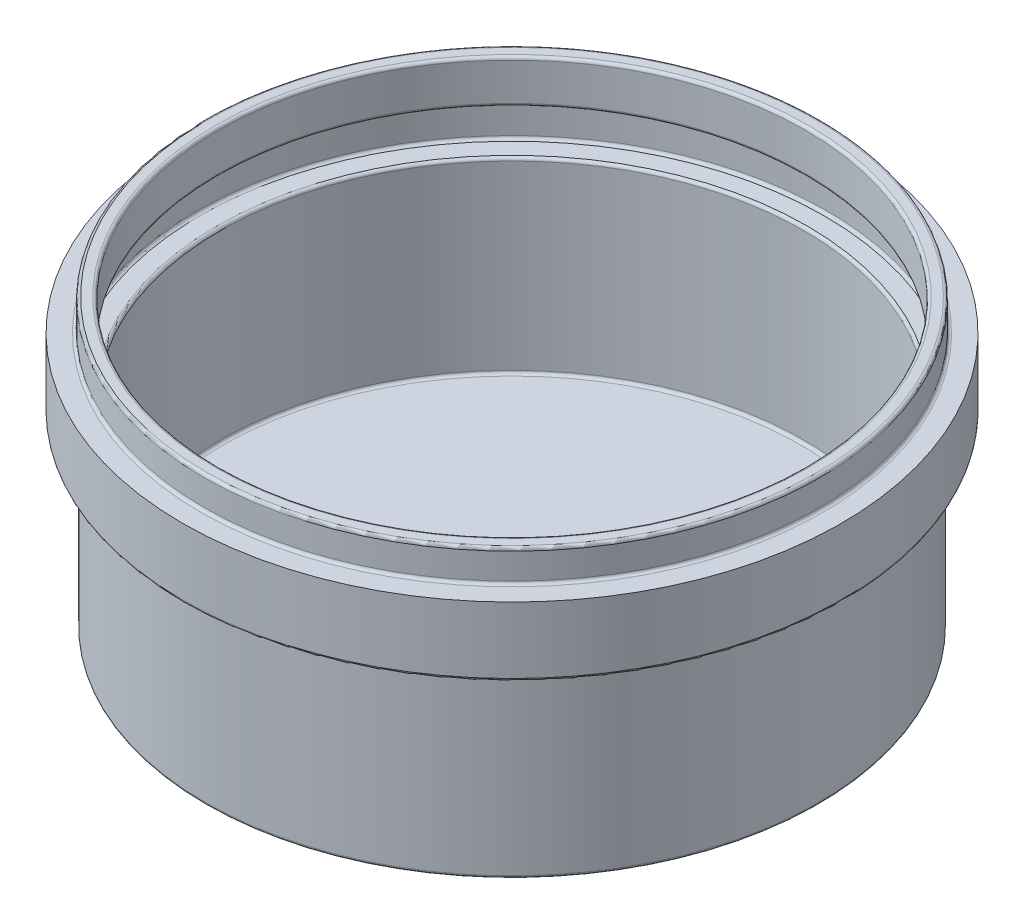
from build123d import *

# Parameters (mm, degrees)
ESBO_O1_R                = 53.25
RESSALTO_EXTRUS_O1_DEPTH = 2.5
ESBO_O2_R                = 53.25
ESBO_O2_R_2              = 50.75
RESSALTO_EXTRUS_O2_DEPTH = 30
ESBO_O3_R                = 57.25
RESSALTO_EXTRUS_O3_DEPTH = 12
ESBO_O6_R                = 53.5
RESSALTO_EXTRUS_O4_DEPTH = 5.5
ESBO_O7_R                = 51
CORTE_EXTRUS_O4_DEPTH    = 7.5
ESBO_O8_R                = 54.75
CORTE_EXTRUS_O5_DEPTH    = 7.5
CORTE_EXTRUS_O6_START    = -7.5
ESBO_O9_R                = 50.75
CORTE_EXTRUS_O6_DEPTH    = 7.5
FILETE1_R                = 0.5
FILETE2_R                = 0.5


with BuildPart() as part:
    # Esboço1 → Ressalto-extrusão1 (new body)
    with BuildSketch(Plane(origin=(0, 0, 0), x_dir=(1, 0, 0), z_dir=(0, 1, 0))):
        Circle(ESBO_O1_R)
    extrude(amount=RESSALTO_EXTRUS_O1_DEPTH)

    # Esboço2 → Ressalto-extrusão2 (add)
    with BuildSketch(Plane(origin=(0, 2.5, 0), x_dir=(1, 0, 0), z_dir=(0, 1, 0))):
        Circle(ESBO_O2_R)
        Circle(ESBO_O2_R_2, mode=Mode.SUBTRACT)
    extrude(amount=RESSALTO_EXTRUS_O2_DEPTH)


with BuildPart() as body_2:
    # Esboço3 → Ressalto-extrusão3 (new body)
    with BuildSketch(Plane(origin=(0, 32.5, 0), x_dir=(1, 0, 0), z_dir=(0, 1, 0))):
        Circle(ESBO_O3_R)
    extrude(amount=RESSALTO_EXTRUS_O3_DEPTH)

    # Esboço6 → Ressalto-extrusão4 (add)
    with BuildSketch(Plane(origin=(0, 44.5, 0), x_dir=(1, 0, 0), z_dir=(0, 1, 0))):
        Circle(ESBO_O6_R)
    extrude(amount=RESSALTO_EXTRUS_O4_DEPTH)

    # Esboço7 → Corte-extrusão4 (cut)
    with BuildSketch(Plane(origin=(0, 50, 0), x_dir=(1, 0, 0), z_dir=(0, 1, 0))):
        Circle(ESBO_O7_R)
    extrude(amount=-CORTE_EXTRUS_O4_DEPTH, mode=Mode.SUBTRACT)

    # Esboço8 → Corte-extrusão5 (cut)
    with BuildSketch(Plane(origin=(0, 42.5, 0), x_dir=(1, 0, 0), z_dir=(0, 1, 0))):
        Circle(ESBO_O8_R)
    extrude(amount=-CORTE_EXTRUS_O5_DEPTH, mode=Mode.SUBTRACT)

    # Esboço9 → Corte-extrusão6 (cut)
    with BuildSketch(Plane(origin=(0, 35, 0), x_dir=(1, 0, 0), z_dir=(0, 1, 0)).offset(CORTE_EXTRUS_O6_START)):
        Circle(ESBO_O9_R)
    extrude(amount=CORTE_EXTRUS_O6_DEPTH, mode=Mode.SUBTRACT)

    # Combinar3: union part
    add(part.part)

    # Filete1
    filete1_edges = [body_2.edges().sort_by_distance(p)[0] for p in [
        (-57.25, 32.5, 0),
        (-51, 50, 0),
        (-53.5, 50, 0),
        (-53.5, 44.5, 0),
        (-53.25, 32.5, 0),
        (-53.25, 0, 0),
    ]]
    fillet(filete1_edges, radius=FILETE1_R)

    # Filete2
    filete2_edges = [body_2.edges().sort_by_distance(p)[0] for p in [
        (-51, 42.5, 0),
        (-54.75, 35, 0),
        (-50.75, 2.5, 0),
        (-50.75, 35, 0),
        (-54.75, 42.5, 0),
    ]]
    fillet(filete2_edges, radius=FILETE2_R)


solid = body_2.part
